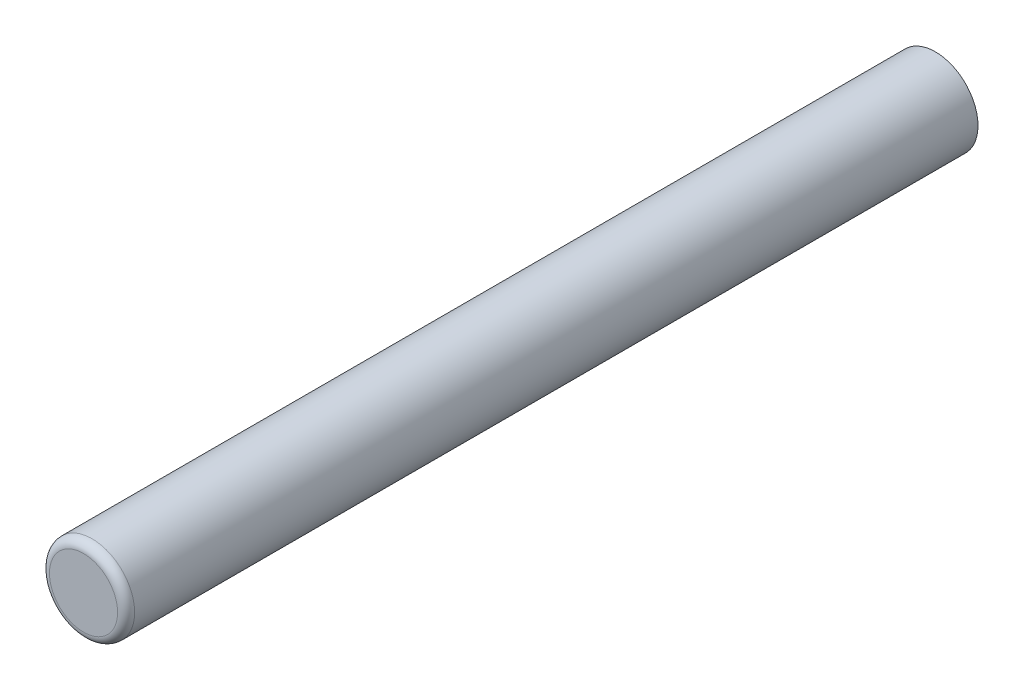
from build123d import *

# Parameters (mm, degrees)
SKETCH1_R           = 3.175
BOSS_EXTRUDE1_DEPTH = 63.5
FILLET1_R           = 0.635


with BuildPart() as part:
    # Sketch1 → Boss-Extrude1 (new body)
    with BuildSketch(Plane.XY):
        Circle(SKETCH1_R)
    extrude(amount=BOSS_EXTRUDE1_DEPTH)

    # Fillet1
    fillet1_edges = [part.edges().sort_by_distance(p)[0] for p in [
        (-3.175, 0, 63.5),
    ]]
    fillet(fillet1_edges, radius=FILLET1_R)


solid = part.part
